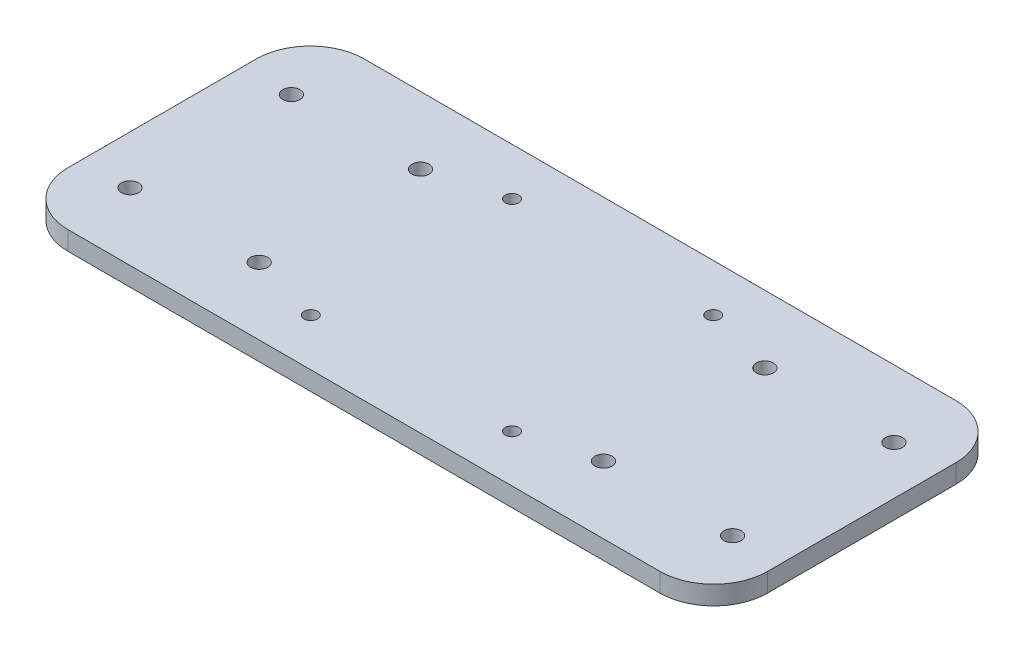
from build123d import *

# Parameters (mm, degrees)
SKETCH1_W           = 130
SKETCH1_H           = 55
SKETCH1_R           = 1.6
SKETCH1_R_2         = 1.25
BOSS_EXTRUDE1_DEPTH = 3.5
FILLET1_R           = 10


with BuildPart() as part:
    # Sketch1 → Boss-Extrude1 (new body)
    with BuildSketch(Plane(origin=(0, 0, 0), x_dir=(1, 0, 0), z_dir=(0, 1, 0))):
        with Locations((65, -27.5)):
            Rectangle(SKETCH1_W, SKETCH1_H)
        with Locations((9, -12.5)):
            Circle(SKETCH1_R, mode=Mode.SUBTRACT)
        with Locations((9, -42.5)):
            Circle(SKETCH1_R, mode=Mode.SUBTRACT)
        with Locations((33, -12.5)):
            Circle(SKETCH1_R, mode=Mode.SUBTRACT)
        with Locations((33, -42.5)):
            Circle(SKETCH1_R, mode=Mode.SUBTRACT)
        with Locations((121, -42.5)):
            Circle(SKETCH1_R, mode=Mode.SUBTRACT)
        with Locations((97, -42.5)):
            Circle(SKETCH1_R, mode=Mode.SUBTRACT)
        with Locations((97, -12.5)):
            Circle(SKETCH1_R, mode=Mode.SUBTRACT)
        with Locations((121, -12.5)):
            Circle(SKETCH1_R, mode=Mode.SUBTRACT)
        with Locations((83.7, -8.8)):
            Circle(SKETCH1_R_2, mode=Mode.SUBTRACT)
        with Locations((83.7, -46.2)):
            Circle(SKETCH1_R_2, mode=Mode.SUBTRACT)
        with Locations((46.3, -46.2)):
            Circle(SKETCH1_R_2, mode=Mode.SUBTRACT)
        with Locations((46.3, -8.8)):
            Circle(SKETCH1_R_2, mode=Mode.SUBTRACT)
    extrude(amount=BOSS_EXTRUDE1_DEPTH)

    # Fillet1
    fillet1_edges = [part.edges().sort_by_distance(p)[0] for p in [
        (0, 1.75, 0),
        (130, 1.75, 0),
        (130, 1.75, 55),
        (0, 1.75, 55),
    ]]
    fillet(fillet1_edges, radius=FILLET1_R)


solid = part.part
